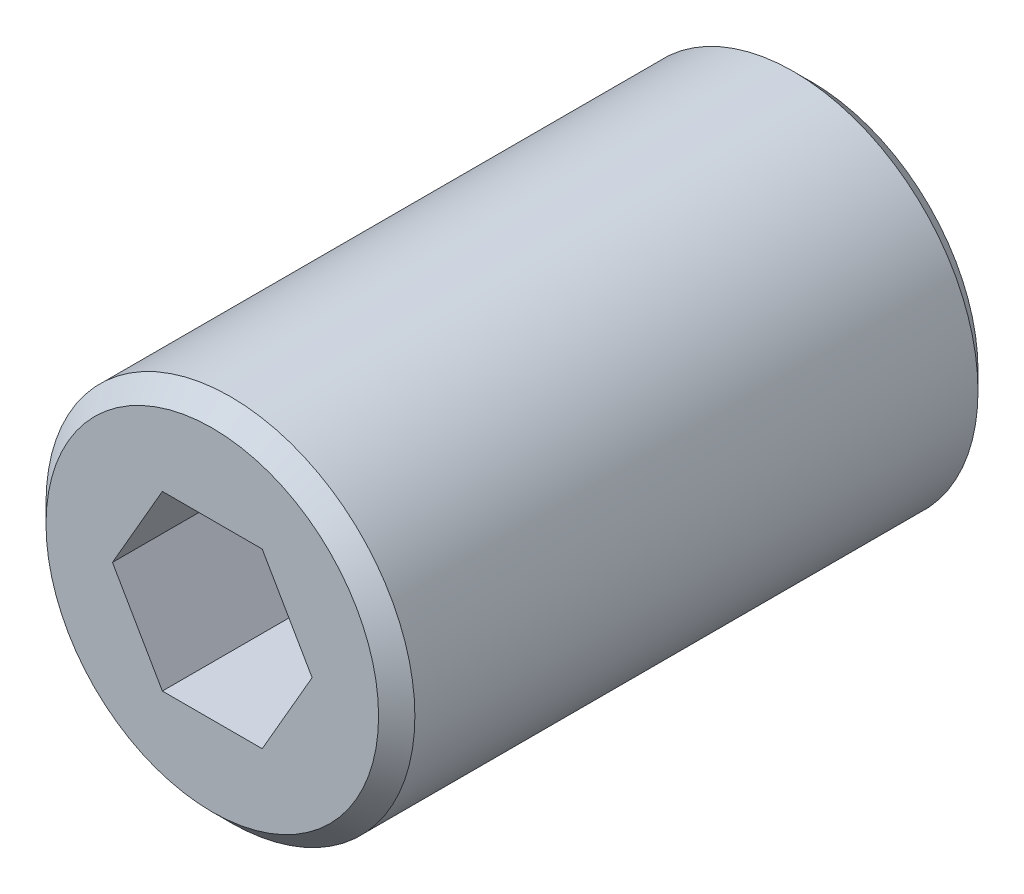
from build123d import *

# Parameters (mm, degrees)
SKETCH1_R           = 10.16
BOSS_EXTRUDE1_DEPTH = 33.02
CHAMFER1_SIZE       = 1


with BuildPart() as part:
    # Sketch1 → Boss-Extrude1 (new body)
    with BuildSketch(Plane.XY):
        Circle(SKETCH1_R)
        Polygon((5.499261314, 0), (2.749630657, 4.7625), (-2.749630657, 4.7625), (-5.499261314, 0), (-2.749630657, -4.7625), (2.749630657, -4.7625), align=None, mode=Mode.SUBTRACT)
    extrude(amount=BOSS_EXTRUDE1_DEPTH)

    # Chamfer1
    chamfer1_edges = [part.edges().sort_by_distance(p)[0] for p in [
        (-10.16, 0, 0),
        (-10.16, 0, 33.02),
    ]]
    chamfer(chamfer1_edges, length=CHAMFER1_SIZE)


solid = part.part
